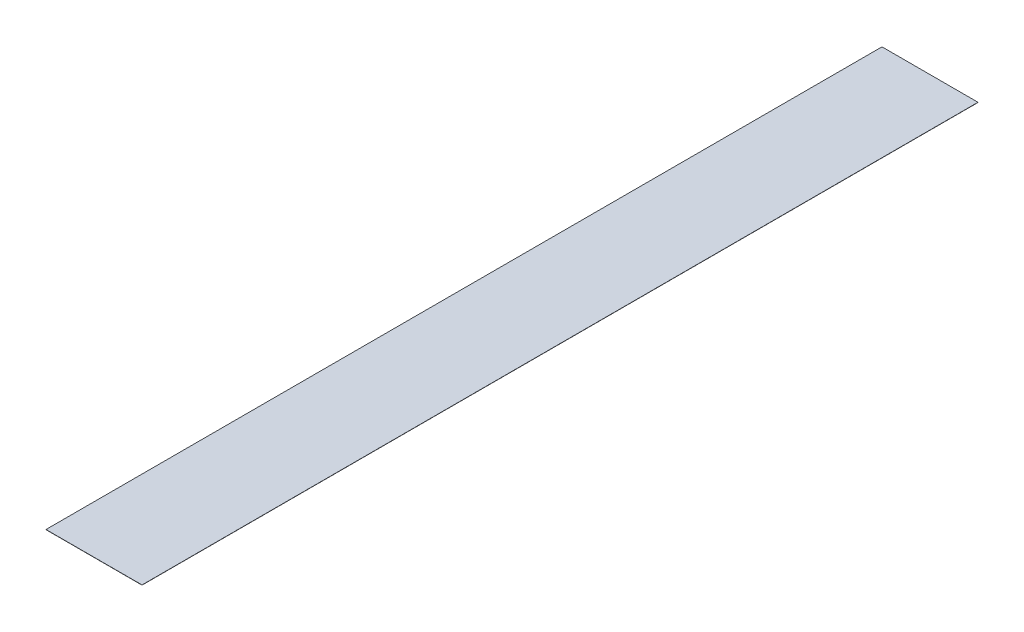
from build123d import *

# Parameters (mm, degrees)
SKETCH1_W           = 23.23
SKETCH1_H           = 203.99
EXTRUDE1_DEPTH      = 0.0508
SKETCH2_W           = 0.2
SKETCH2_H           = 203.99
BOSS_EXTRUDE1_DEPTH = 0.0508


with BuildPart() as part:
    # Sketch1 → Extrude1 (new body)
    with BuildSketch(Plane(origin=(0, 0, 0), x_dir=(1, 0, 0), z_dir=(0, 1, 0))):
        Rectangle(SKETCH1_W, SKETCH1_H)
    extrude(amount=EXTRUDE1_DEPTH)

    # Sketch2 → Boss-Extrude1 (add, through all)
    with BuildSketch(Plane(origin=(0, 0.0508, 0), x_dir=(1, 0, 0), z_dir=(0, 1, 0))):
        with Locations((-11.715, 0)):
            Rectangle(SKETCH2_W, SKETCH2_H)
    extrude(amount=-BOSS_EXTRUDE1_DEPTH)


solid = part.part
